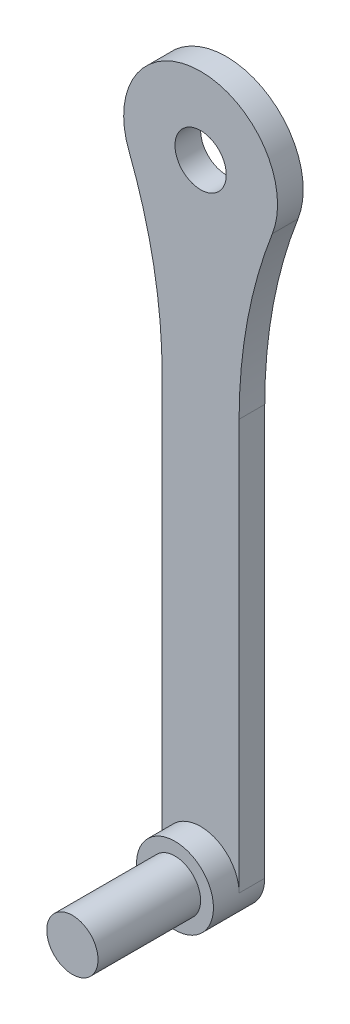
from build123d import *

# Parameters (mm, degrees)
BOSS_EXTRUDE1_DEPTH            = 5
SKETCH2_R                      = 7.5
BOSS_EXTRUDE2_DEPTH            = 5
SKETCH3_R                      = 5
BOSS_EXTRUDE3_DEPTH            = 20
F_10_0_10_DIAMETER_HOLE1_D     = 10
F_10_0_10_DIAMETER_HOLE1_DEPTH = 30
FILLET1_R                      = 95.416666667


with BuildPart() as part:
    # Sketch1 → Boss-Extrude1 (new body)
    with BuildSketch(Plane(origin=(0, 0, 0), x_dir=(-1, 0, 0), z_dir=(0, 0, -1))):
        with BuildLine():
            Line((7.499999998, -120), (7.499999998, -12.990381057))
            ThreePointArc((7.499999998, -12.990381057), (-1e-09, 15.000000001), (-7.5, -12.990381057))
            Line((-7.5, -12.990381057), (-7.5, -120))
            ThreePointArc((-7.5, -120), (-1e-09, -127.499999999), (7.499999998, -120))
        make_face()
    extrude(amount=-BOSS_EXTRUDE1_DEPTH)

    # Sketch2 → Boss-Extrude2 (add)
    with BuildSketch(Plane.XY.offset(5)):
        with Locations((0, -120)):
            Circle(SKETCH2_R)
    extrude(amount=BOSS_EXTRUDE2_DEPTH)

    # Sketch3 → Boss-Extrude3 (add)
    with BuildSketch(Plane.XY.offset(10)):
        with Locations((0, -120)):
            Circle(SKETCH3_R)
    extrude(amount=BOSS_EXTRUDE3_DEPTH)

    # Ø10.0 (10) Diameter Hole1
    with Locations(Plane(origin=(0, 0, 0), x_dir=(-1, 0, 0), z_dir=(0, 0, -1))):
        with Locations((0, 0)):
            Hole(F_10_0_10_DIAMETER_HOLE1_D / 2, depth=F_10_0_10_DIAMETER_HOLE1_DEPTH)

    # Fillet1
    fillet1_edges = [part.edges().sort_by_distance(p)[0] for p in [
        (7.5, -12.990381057, 2.5),
        (-7.499999998, -12.990381057, 2.5),
    ]]
    fillet(fillet1_edges, radius=FILLET1_R)


solid = part.part
